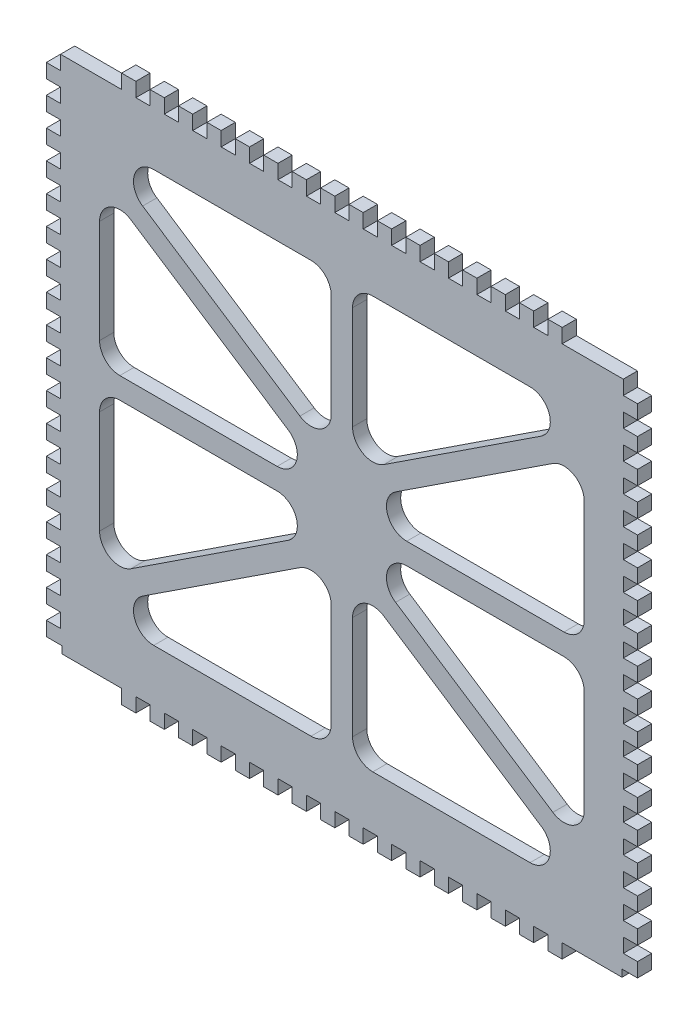
from build123d import *

# Parameters (mm, degrees)
SKETCH1_W           = 166.42
SKETCH1_H           = 146
BOSS_EXTRUDE1_DEPTH = 4
SKETCH2_W           = 4.36
SKETCH2_H           = 2
SKETCH2_W_2         = 4
SKETCH2_H_2         = 4
CUT_EXTRUDE1_DEPTH  = 4
SKETCH3_W           = 4
SKETCH3_H           = 4
BOSS_EXTRUDE2_DEPTH = 4


with BuildPart() as part:
    # Sketch1 → Boss-Extrude1 (new body)
    with BuildSketch(Plane.XY):
        Rectangle(SKETCH1_W, SKETCH1_H)
        with BuildLine():
            Line((-52.966359464, 58), (-8.697048922, 58))
            ThreePointArc((-8.697048922, 58), (-4.668626997, 56.331373003), (-3, 52.302951078))
            Line((-3, 52.302951078), (-3, 23.23724247))
            ThreePointArc((-3, 23.23724247), (-5.991223136, 18.223773288), (-11.82382215, 18.474926268))
            Line((-11.82382215, 18.474926268), (-56.093132692, 47.540634876))
            ThreePointArc((-56.093132692, 47.540634876), (-58.424725282, 53.934701371), (-52.966359464, 58))
        make_face(mode=Mode.SUBTRACT)
        with BuildLine():
            Line((-59.38617785, 42.525073732), (-15.116867308, 13.459365124))
            ThreePointArc((-15.116867308, 13.459365124), (-12.785274718, 7.065298629), (-18.243640536, 3))
            Line((-18.243640536, 3), (-62.512951078, 3))
            ThreePointArc((-62.512951078, 3), (-66.541373003, 4.668626997), (-68.21, 8.697048922))
            Line((-68.21, 8.697048922), (-68.21, 37.76275753))
            ThreePointArc((-68.21, 37.76275753), (-65.218776864, 42.776226712), (-59.38617785, 42.525073732))
        make_face(mode=Mode.SUBTRACT)
        with BuildLine():
            Line((68.21, 8.697048922), (68.21, 37.76275753))
            ThreePointArc((68.21, 37.76275753), (65.218776864, 42.776226712), (59.38617785, 42.525073732))
            Line((59.38617785, 42.525073732), (15.116867308, 13.459365124))
            ThreePointArc((15.116867308, 13.459365124), (12.785274718, 7.065298629), (18.243640536, 3))
            Line((18.243640536, 3), (62.512951078, 3))
            ThreePointArc((62.512951078, 3), (66.541373003, 4.668626997), (68.21, 8.697048922))
        make_face(mode=Mode.SUBTRACT)
        with BuildLine():
            Line((3, 23.23724247), (3, 52.302951078))
            ThreePointArc((3, 52.302951078), (4.668626997, 56.331373003), (8.697048922, 58))
            Line((8.697048922, 58), (52.966359464, 58))
            ThreePointArc((52.966359464, 58), (58.424725282, 53.934701371), (56.093132692, 47.540634876))
            Line((56.093132692, 47.540634876), (11.82382215, 18.474926268))
            ThreePointArc((11.82382215, 18.474926268), (5.991223136, 18.223773288), (3, 23.23724247))
        make_face(mode=Mode.SUBTRACT)
        with BuildLine():
            Line((52.966359464, -58), (8.697048922, -58))
            ThreePointArc((8.697048922, -58), (4.668626997, -56.331373003), (3, -52.302951078))
            Line((3, -52.302951078), (3, -23.23724247))
            ThreePointArc((3, -23.23724247), (5.991223136, -18.223773288), (11.82382215, -18.474926268))
            Line((11.82382215, -18.474926268), (56.093132692, -47.540634876))
            ThreePointArc((56.093132692, -47.540634876), (58.424725282, -53.934701371), (52.966359464, -58))
        make_face(mode=Mode.SUBTRACT)
        with BuildLine():
            Line((59.38617785, -42.525073732), (15.116867308, -13.459365124))
            ThreePointArc((15.116867308, -13.459365124), (12.785274718, -7.065298629), (18.243640536, -3))
            Line((18.243640536, -3), (62.512951078, -3))
            ThreePointArc((62.512951078, -3), (66.541373003, -4.668626997), (68.21, -8.697048922))
            Line((68.21, -8.697048922), (68.21, -37.76275753))
            ThreePointArc((68.21, -37.76275753), (65.218776864, -42.776226712), (59.38617785, -42.525073732))
        make_face(mode=Mode.SUBTRACT)
        with BuildLine():
            Line((-68.21, -8.697048922), (-68.21, -37.76275753))
            ThreePointArc((-68.21, -37.76275753), (-65.218776864, -42.776226712), (-59.38617785, -42.525073732))
            Line((-59.38617785, -42.525073732), (-15.116867308, -13.459365124))
            ThreePointArc((-15.116867308, -13.459365124), (-12.785274718, -7.065298629), (-18.243640536, -3))
            Line((-18.243640536, -3), (-62.512951078, -3))
            ThreePointArc((-62.512951078, -3), (-66.541373003, -4.668626997), (-68.21, -8.697048922))
        make_face(mode=Mode.SUBTRACT)
        with BuildLine():
            Line((-3, -23.23724247), (-3, -52.302951078))
            ThreePointArc((-3, -52.302951078), (-4.668626997, -56.331373003), (-8.697048922, -58))
            Line((-8.697048922, -58), (-52.966359464, -58))
            ThreePointArc((-52.966359464, -58), (-58.424725282, -53.934701371), (-56.093132692, -47.540634876))
            Line((-56.093132692, -47.540634876), (-11.82382215, -18.474926268))
            ThreePointArc((-11.82382215, -18.474926268), (-5.991223136, -18.223773288), (-3, -23.23724247))
        make_face(mode=Mode.SUBTRACT)
    extrude(amount=BOSS_EXTRUDE1_DEPTH)

    # Sketch2 → Cut-Extrude1 (cut)
    with BuildSketch(Plane.XY.offset(4)):
        with Locations((-81.03, -72)):
            Rectangle(SKETCH2_W, SKETCH2_H)
        with Locations((-81.21, 63)):
            Rectangle(SKETCH2_W_2, SKETCH2_H_2)
        with Locations((-81.21, 55)):
            Rectangle(SKETCH2_W_2, SKETCH2_H_2)
        with Locations((-81.21, 47)):
            Rectangle(SKETCH2_W_2, SKETCH2_H_2)
        with Locations((-81.21, 39)):
            Rectangle(SKETCH2_W_2, SKETCH2_H_2)
        with Locations((-81.21, 31)):
            Rectangle(SKETCH2_W_2, SKETCH2_H_2)
        with Locations((-81.21, 23)):
            Rectangle(SKETCH2_W_2, SKETCH2_H_2)
        with Locations((-81.21, 15)):
            Rectangle(SKETCH2_W_2, SKETCH2_H_2)
        with Locations((-81.21, 7)):
            Rectangle(SKETCH2_W_2, SKETCH2_H_2)
        with Locations((-81.21, -1)):
            Rectangle(SKETCH2_W_2, SKETCH2_H_2)
        with Locations((-81.21, -9)):
            Rectangle(SKETCH2_W_2, SKETCH2_H_2)
        with Locations((-81.21, -17)):
            Rectangle(SKETCH2_W_2, SKETCH2_H_2)
        with Locations((-81.21, -25)):
            Rectangle(SKETCH2_W_2, SKETCH2_H_2)
        with Locations((-81.21, -33)):
            Rectangle(SKETCH2_W_2, SKETCH2_H_2)
        with Locations((-81.21, -41)):
            Rectangle(SKETCH2_W_2, SKETCH2_H_2)
        with Locations((81.21, -65)):
            Rectangle(SKETCH2_W_2, SKETCH2_H_2)
        with Locations((-81.21, -49)):
            Rectangle(SKETCH2_W_2, SKETCH2_H_2)
        with Locations((81.21, -57)):
            Rectangle(SKETCH2_W_2, SKETCH2_H_2)
        with Locations((81.21, -49)):
            Rectangle(SKETCH2_W_2, SKETCH2_H_2)
        with Locations((81.21, 71)):
            Rectangle(SKETCH2_W_2, SKETCH2_H_2)
        with Locations((81.21, -41)):
            Rectangle(SKETCH2_W_2, SKETCH2_H_2)
        with Locations((81.21, -33)):
            Rectangle(SKETCH2_W_2, SKETCH2_H_2)
        with Locations((81.21, -25)):
            Rectangle(SKETCH2_W_2, SKETCH2_H_2)
        with Locations((81.21, -17)):
            Rectangle(SKETCH2_W_2, SKETCH2_H_2)
        with Locations((81.21, -9)):
            Rectangle(SKETCH2_W_2, SKETCH2_H_2)
        with Locations((81.21, -1)):
            Rectangle(SKETCH2_W_2, SKETCH2_H_2)
        with Locations((-81.21, 71)):
            Rectangle(SKETCH2_W_2, SKETCH2_H_2)
        with Locations((81.21, 7)):
            Rectangle(SKETCH2_W_2, SKETCH2_H_2)
        with Locations((81.21, 15)):
            Rectangle(SKETCH2_W_2, SKETCH2_H_2)
        with Locations((81.21, 23)):
            Rectangle(SKETCH2_W_2, SKETCH2_H_2)
        with Locations((81.21, 31)):
            Rectangle(SKETCH2_W_2, SKETCH2_H_2)
        with Locations((81.21, 39)):
            Rectangle(SKETCH2_W_2, SKETCH2_H_2)
        with Locations((81.21, 47)):
            Rectangle(SKETCH2_W_2, SKETCH2_H_2)
        with Locations((-81.21, -57)):
            Rectangle(SKETCH2_W_2, SKETCH2_H_2)
        with Locations((-81.21, -65)):
            Rectangle(SKETCH2_W_2, SKETCH2_H_2)
        with Locations((81.21, 55)):
            Rectangle(SKETCH2_W_2, SKETCH2_H_2)
        with Locations((81.21, 63)):
            Rectangle(SKETCH2_W_2, SKETCH2_H_2)
        with Locations((81.03, -72)):
            Rectangle(SKETCH2_W, SKETCH2_H)
    extrude(amount=-CUT_EXTRUDE1_DEPTH, mode=Mode.SUBTRACT)

    # Sketch3 → Boss-Extrude2 (add)
    with BuildSketch(Plane.XY.offset(4)):
        with Locations((-4, 75)):
            Rectangle(SKETCH3_W, SKETCH3_H)
        with Locations((-12, 75)):
            Rectangle(SKETCH3_W, SKETCH3_H)
        with Locations((-20, 75)):
            Rectangle(SKETCH3_W, SKETCH3_H)
        with Locations((-28, 75)):
            Rectangle(SKETCH3_W, SKETCH3_H)
        with Locations((-36, 75)):
            Rectangle(SKETCH3_W, SKETCH3_H)
        with Locations((-44, 75)):
            Rectangle(SKETCH3_W, SKETCH3_H)
        with Locations((-52, 75)):
            Rectangle(SKETCH3_W, SKETCH3_H)
        with Locations((-60, 75)):
            Rectangle(SKETCH3_W, SKETCH3_H)
        with Locations((60, 75)):
            Rectangle(SKETCH3_W, SKETCH3_H)
        with Locations((52, 75)):
            Rectangle(SKETCH3_W, SKETCH3_H)
        with Locations((44, 75)):
            Rectangle(SKETCH3_W, SKETCH3_H)
        with Locations((36, 75)):
            Rectangle(SKETCH3_W, SKETCH3_H)
        with Locations((28, 75)):
            Rectangle(SKETCH3_W, SKETCH3_H)
        with Locations((20, 75)):
            Rectangle(SKETCH3_W, SKETCH3_H)
        with Locations((12, 75)):
            Rectangle(SKETCH3_W, SKETCH3_H)
        with Locations((4, 75)):
            Rectangle(SKETCH3_W, SKETCH3_H)
        with Locations((4, -75)):
            Rectangle(SKETCH3_W, SKETCH3_H)
        with Locations((12, -75)):
            Rectangle(SKETCH3_W, SKETCH3_H)
        with Locations((20, -75)):
            Rectangle(SKETCH3_W, SKETCH3_H)
        with Locations((28, -75)):
            Rectangle(SKETCH3_W, SKETCH3_H)
        with Locations((36, -75)):
            Rectangle(SKETCH3_W, SKETCH3_H)
        with Locations((44, -75)):
            Rectangle(SKETCH3_W, SKETCH3_H)
        with Locations((52, -75)):
            Rectangle(SKETCH3_W, SKETCH3_H)
        with Locations((60, -75)):
            Rectangle(SKETCH3_W, SKETCH3_H)
        with Locations((-60, -75)):
            Rectangle(SKETCH3_W, SKETCH3_H)
        with Locations((-52, -75)):
            Rectangle(SKETCH3_W, SKETCH3_H)
        with Locations((-44, -75)):
            Rectangle(SKETCH3_W, SKETCH3_H)
        with Locations((-36, -75)):
            Rectangle(SKETCH3_W, SKETCH3_H)
        with Locations((-28, -75)):
            Rectangle(SKETCH3_W, SKETCH3_H)
        with Locations((-20, -75)):
            Rectangle(SKETCH3_W, SKETCH3_H)
        with Locations((-12, -75)):
            Rectangle(SKETCH3_W, SKETCH3_H)
        with Locations((-4, -75)):
            Rectangle(SKETCH3_W, SKETCH3_H)
    extrude(amount=-BOSS_EXTRUDE2_DEPTH)


solid = part.part
